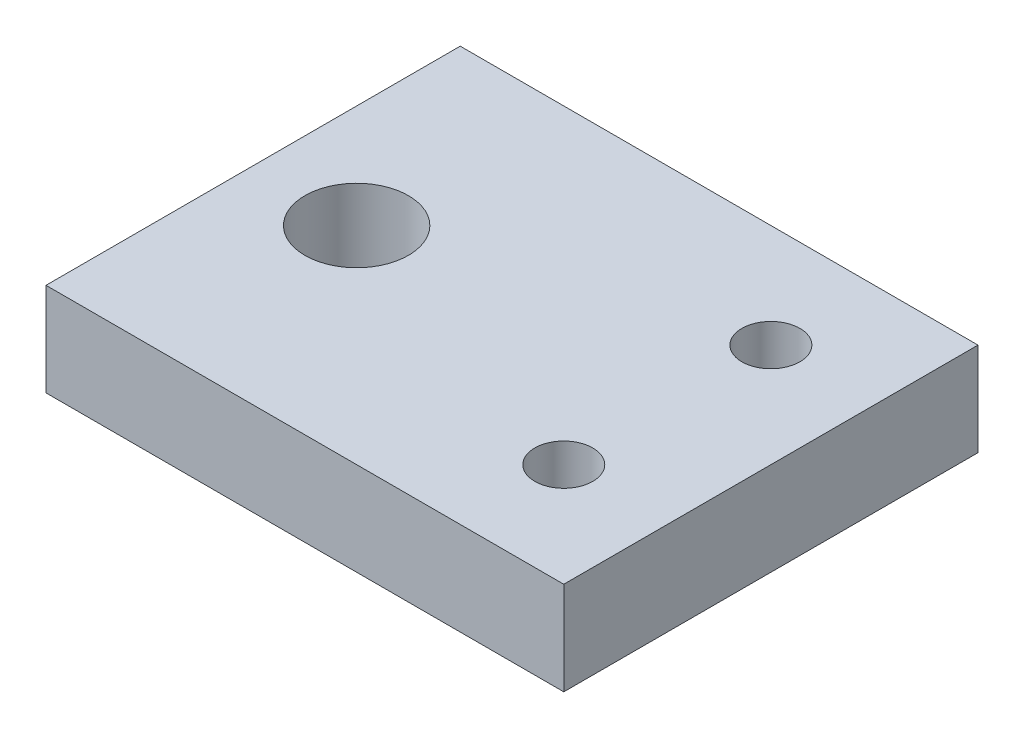
from build123d import *

# Parameters (mm, degrees)
SKETCH1_W           = 25
SKETCH1_H           = 20
BOSS_EXTRUDE1_DEPTH = 4.5
SKETCH1_4_R         = 2.5
SKETCH1_4_R_2       = 1.4
CUT_EXTRUDE1_DEPTH  = 4.5


with BuildPart() as part:
    # Sketch1 → Boss-Extrude1 (new body)
    with BuildSketch(Plane(origin=(0, 0, 0), x_dir=(1, 0, 0), z_dir=(0, 1, 0))):
        with Locations((12.5, 10)):
            Rectangle(SKETCH1_W, SKETCH1_H)
    extrude(amount=BOSS_EXTRUDE1_DEPTH)

    # Sketch1_4 → Cut-Extrude1 (cut)
    with BuildSketch(Plane(origin=(0, 0, 0), x_dir=(1, 0, 0), z_dir=(0, 1, 0))):
        with Locations((5, 10)):
            Circle(SKETCH1_4_R)
        with Locations((20, 15)):
            Circle(SKETCH1_4_R_2)
        with Locations((20, 5)):
            Circle(SKETCH1_4_R_2)
    extrude(amount=CUT_EXTRUDE1_DEPTH, mode=Mode.SUBTRACT)


solid = part.part
